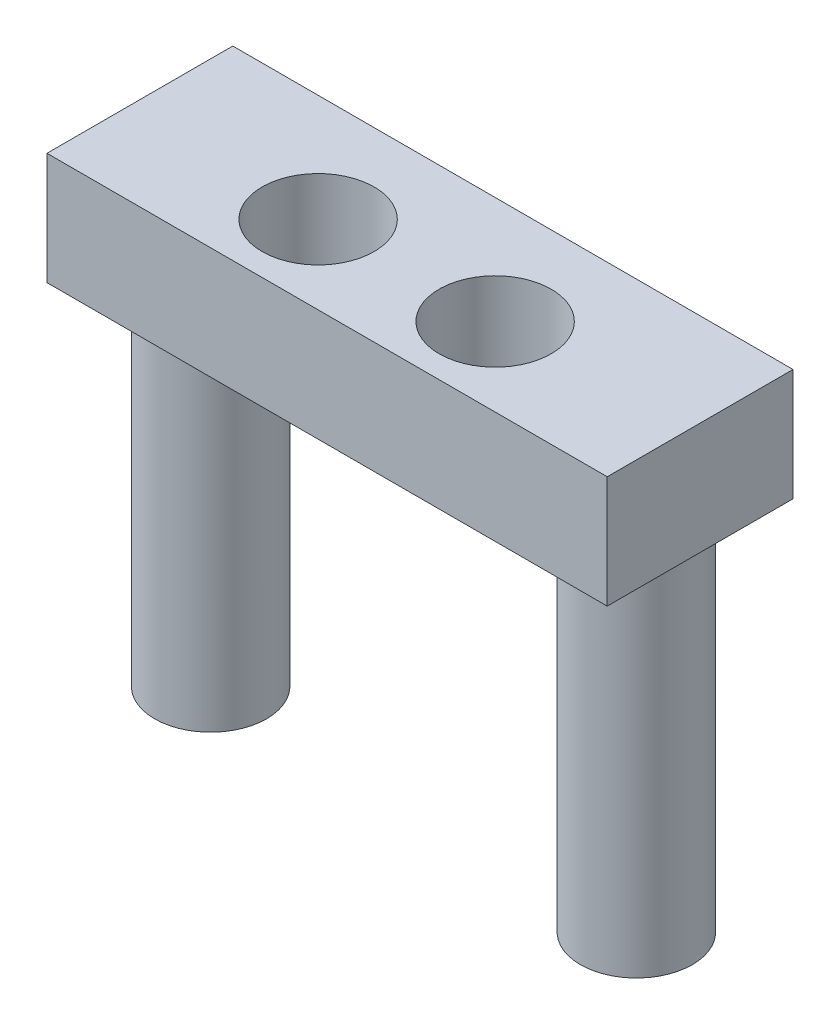
from build123d import *

# Parameters (mm, degrees)
SKETCH1_W           = 50
SKETCH1_H           = 16.582990108
SKETCH1_R           = 5
BOSS_EXTRUDE1_DEPTH = 10
SKETCH2_R           = 5
BOSS_EXTRUDE2_DEPTH = 32.5158
SKETCH3_R           = 1.75
CUT_EXTRUDE1_DEPTH  = 10


with BuildPart() as part:
    # Sketch1 → Boss-Extrude1 (new body)
    with BuildSketch(Plane(origin=(0, 0, 0), x_dir=(1, 0, 0), z_dir=(0, 1, 0))):
        with Locations((9.061664817, 20.692573909)):
            Rectangle(SKETCH1_W, SKETCH1_H)
        with Locations((1.261664817, 19.401078855)):
            Circle(SKETCH1_R, mode=Mode.SUBTRACT)
        with Locations((17.061664817, 19.401078855)):
            Circle(SKETCH1_R, mode=Mode.SUBTRACT)
    extrude(amount=BOSS_EXTRUDE1_DEPTH)

    # Sketch2 → Boss-Extrude2 (add)
    with BuildSketch(Plane.XZ):
        with Locations((28.061664817, -21.004215915)):
            Circle(SKETCH2_R)
        with Locations((-9.938335183, -21.004215915)):
            Circle(SKETCH2_R)
    extrude(amount=BOSS_EXTRUDE2_DEPTH)

    # Sketch3 → Cut-Extrude1 (cut)
    with BuildSketch(Plane.XZ.offset(32.5158)):
        with Locations((28.061664817, -21.004215915)):
            Circle(SKETCH3_R)
        with Locations((-9.938335183, -21.004215915)):
            Circle(SKETCH3_R)
    extrude(amount=-CUT_EXTRUDE1_DEPTH, mode=Mode.SUBTRACT)


solid = part.part
